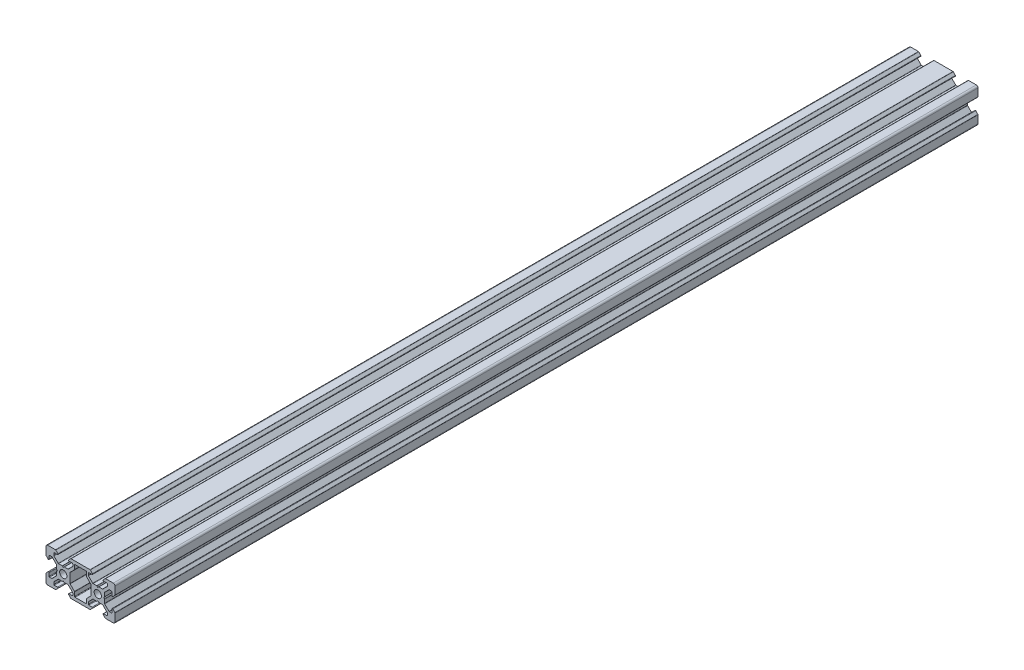
from build123d import *

# Parameters (mm, degrees)
SKETCH_1_R      = 2.1
EXTRUDE_1_DEPTH = 500
FILLET_1_R      = 1
FILLET_2_R      = 0.3


with BuildPart() as part:
    # Эскиз1 → Бобышка-Вытянуть1 (new body)
    with BuildSketch(Plane.XY):
        Polygon((-10, -10), (-10, -4.4), (-8.2, -2.6), (-8.2, -5.499339828), (-6.56, -5.499339828), (-3.900660172, -2.84), (-3.900660172, -0.5), (-3.400660172, 0), (-3.900660172, 0.5), (-3.900660172, 2.84), (-6.56, 5.499339828), (-8.2, 5.499339828), (-8.2, 2.6), (-10, 4.4), (-10, 10), (-4.4, 10), (-2.6, 8.2), (-5.499339828, 8.2), (-5.499339828, 6.56), (-2.84, 3.900660172), (-0.5, 3.900660172), (0, 3.400660172), (0.5, 3.900660172), (2.84, 3.900660172), (5.499339828, 6.56), (5.499339828, 8.2), (2.6, 8.2), (4.4, 10), (15.6, 10), (17.4, 8.2), (14.500660172, 8.2), (14.500660172, 6.56), (17.16, 3.900660172), (19.5, 3.900660172), (20, 3.400660172), (20.5, 3.900660172), (22.84, 3.900660172), (25.499339828, 6.56), (25.499339828, 8.2), (22.6, 8.2), (24.4, 10), (30, 10), (30, 4.4), (28.2, 2.6), (28.2, 5.499339828), (26.56, 5.499339828), (23.900660172, 2.84), (23.900660172, 0.5), (23.400660172, 0), (23.900660172, -0.5), (23.900660172, -2.84), (26.56, -5.499339828), (28.2, -5.499339828), (28.2, -2.6), (30, -4.4), (30, -10), (24.4, -10), (22.6, -8.2), (25.499339828, -8.2), (25.499339828, -6.56), (22.84, -3.900660172), (20.5, -3.900660172), (20, -3.400660172), (19.5, -3.900660172), (17.16, -3.900660172), (14.500660172, -6.56), (14.500660172, -8.2), (17.4, -8.2), (15.6, -10), (4.4, -10), (2.6, -8.2), (5.499339828, -8.2), (5.499339828, -6.56), (2.84, -3.900660172), (0.5, -3.900660172), (0, -3.400660172), (-0.5, -3.900660172), (-2.84, -3.900660172), (-5.499339828, -6.56), (-5.499339828, -8.2), (-2.6, -8.2), (-4.4, -10), align=None)
        Circle(SKETCH_1_R, mode=Mode.SUBTRACT)
        with Locations((20, 0)):
            Circle(SKETCH_1_R, mode=Mode.SUBTRACT)
        Polygon((3.900660172, -0.5), (3.900660172, 0.5), (3.900660172, 2.84), (6.56, 5.499339828), (6.56, 8.2), (13.44, 8.2), (13.44, 5.499339828), (16.099339828, 2.84), (16.099339828, 0.5), (16.099339828, -0.5), (16.099339828, -2.84), (13.44, -5.499339828), (13.44, -8.2), (6.56, -8.2), (6.56, -5.499339828), (3.900660172, -2.84), align=None, mode=Mode.SUBTRACT)
    extrude(amount=EXTRUDE_1_DEPTH)

    # Скругление1
    fillet_1_edges = [part.edges().sort_by_distance(p)[0] for p in [
        (30, -10, 250),
        (30, 10, 250),
        (-10, 10, 250),
        (-10, -10, 250),
    ]]
    fillet(fillet_1_edges, radius=FILLET_1_R)

    # Скругление2
    fillet_2_edges = [part.edges().sort_by_distance(p)[0] for p in [
        (2.84, -3.900660172, 250),
        (5.499339828, -6.56, 250),
        (5.499339828, -8.2, 250),
        (2.6, -8.2, 250),
        (4.4, -10, 250),
        (15.6, -10, 250),
        (17.4, -8.2, 250),
        (14.500660172, -8.2, 250),
        (14.500660172, -6.56, 250),
        (17.16, -3.900660172, 250),
        (19.5, -3.900660172, 250),
        (20.5, -3.900660172, 250),
        (22.84, -3.900660172, 250),
        (25.499339828, -6.56, 250),
        (25.499339828, -8.2, 250),
        (22.6, -8.2, 250),
        (24.4, -10, 250),
        (30, -4.4, 250),
        (28.2, -2.6, 250),
        (28.2, -5.499339828, 250),
        (26.56, -5.499339828, 250),
        (23.900660172, -2.84, 250),
        (23.900660172, -0.5, 250),
        (23.900660172, 0.5, 250),
        (23.900660172, 2.84, 250),
        (26.56, 5.499339828, 250),
        (28.2, 5.499339828, 250),
        (28.2, 2.6, 250),
        (30, 4.4, 250),
        (24.4, 10, 250),
        (22.6, 8.2, 250),
        (25.499339828, 8.2, 250),
        (25.499339828, 6.56, 250),
        (22.84, 3.900660172, 250),
        (20.5, 3.900660172, 250),
        (19.5, 3.900660172, 250),
        (17.16, 3.900660172, 250),
        (14.500660172, 6.56, 250),
        (14.500660172, 8.2, 250),
        (17.4, 8.2, 250),
        (15.6, 10, 250),
        (4.4, 10, 250),
        (2.6, 8.2, 250),
        (5.499339828, 8.2, 250),
        (5.499339828, 6.56, 250),
        (2.84, 3.900660172, 250),
        (0.5, 3.900660172, 250),
        (-0.5, 3.900660172, 250),
        (-2.84, 3.900660172, 250),
        (-5.499339828, 6.56, 250),
        (-5.499339828, 8.2, 250),
        (-2.6, 8.2, 250),
        (-4.4, 10, 250),
        (-10, 4.4, 250),
        (-8.2, 2.6, 250),
        (-8.2, 5.499339828, 250),
        (-6.56, 5.499339828, 250),
        (-3.900660172, 2.84, 250),
        (-3.900660172, 0.5, 250),
        (-3.900660172, -0.5, 250),
        (-3.900660172, -2.84, 250),
        (-6.56, -5.499339828, 250),
        (-8.2, -5.499339828, 250),
        (-8.2, -2.6, 250),
        (-10, -4.4, 250),
        (13.44, -8.2, 250),
        (13.44, -5.499339828, 250),
        (16.099339828, -2.84, 250),
        (16.099339828, 2.84, 250),
        (13.44, 5.499339828, 250),
        (13.44, 8.2, 250),
        (6.56, 8.2, 250),
        (6.56, 5.499339828, 250),
        (3.900660172, 2.84, 250),
        (3.900660172, -2.84, 250),
        (6.56, -5.499339828, 250),
        (6.56, -8.2, 250),
        (-2.6, -8.2, 250),
        (-5.499339828, -8.2, 250),
        (-5.499339828, -6.56, 250),
        (-2.84, -3.900660172, 250),
        (-0.5, -3.900660172, 250),
        (0.5, -3.900660172, 250),
    ]]
    fillet(fillet_2_edges, radius=FILLET_2_R)


solid = part.part
